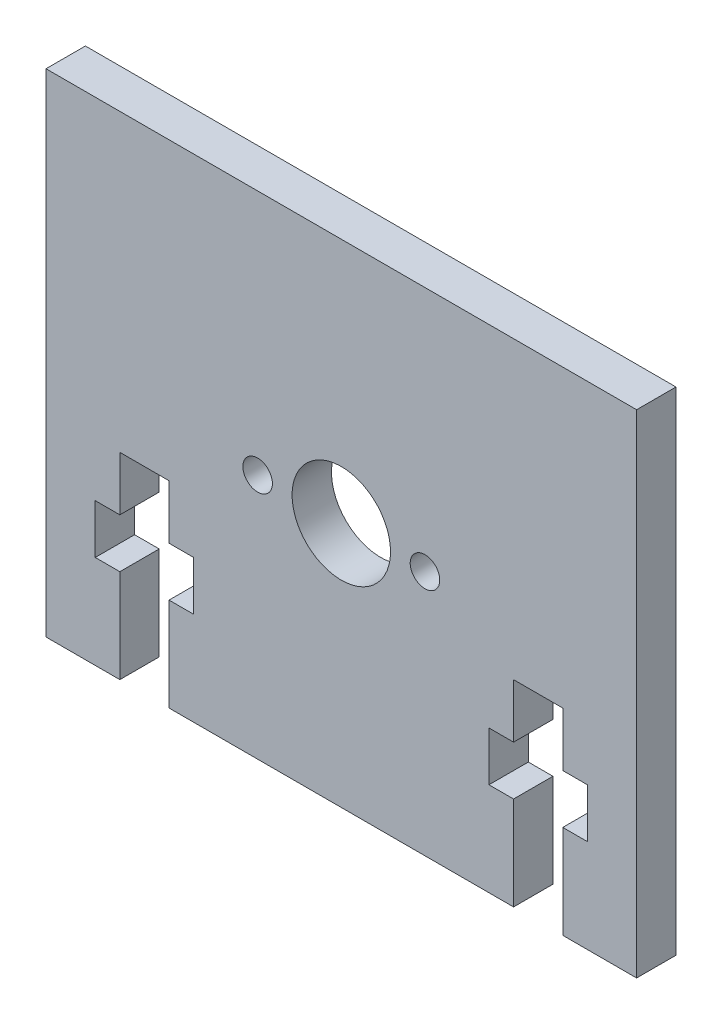
from build123d import *

# Parameters (mm, degrees)
SKETCH1_W           = 60
SKETCH1_H           = 50
SKETCH1_R           = 5
SKETCH1_R_2         = 1.5
BOSS_EXTRUDE1_DEPTH = 4
CUT_EXTRUDE1_DEPTH  = 5


with BuildPart() as part:
    # Sketch1 → Boss-Extrude1 (new body)
    with BuildSketch(Plane.XY):
        Rectangle(SKETCH1_W, SKETCH1_H)
        Circle(SKETCH1_R, mode=Mode.SUBTRACT)
        with Locations((-8.5, 0)):
            Circle(SKETCH1_R_2, mode=Mode.SUBTRACT)
        with Locations((8.5, 0)):
            Circle(SKETCH1_R_2, mode=Mode.SUBTRACT)
    extrude(amount=BOSS_EXTRUDE1_DEPTH)

    # Sketch2 → Cut-Extrude1 (cut, through all)
    with BuildSketch(Plane.XY.offset(4)):
        Polygon((-17.5, -5), (-22.5, -5), (-22.5, -10.5), (-25, -10.5), (-25, -15.5), (-22.5, -15.5), (-22.5, -25), (-17.5, -25), (-17.5, -15.5), (-15, -15.5), (-15, -10.5), (-17.5, -10.5), align=None)
        Polygon((22.5, -5), (17.5, -5), (17.5, -10.5), (15, -10.5), (15, -15.5), (17.5, -15.5), (17.5, -25), (22.5, -25), (22.5, -15.5), (25, -15.5), (25, -10.5), (22.5, -10.5), align=None)
    extrude(amount=-CUT_EXTRUDE1_DEPTH, mode=Mode.SUBTRACT)


solid = part.part
